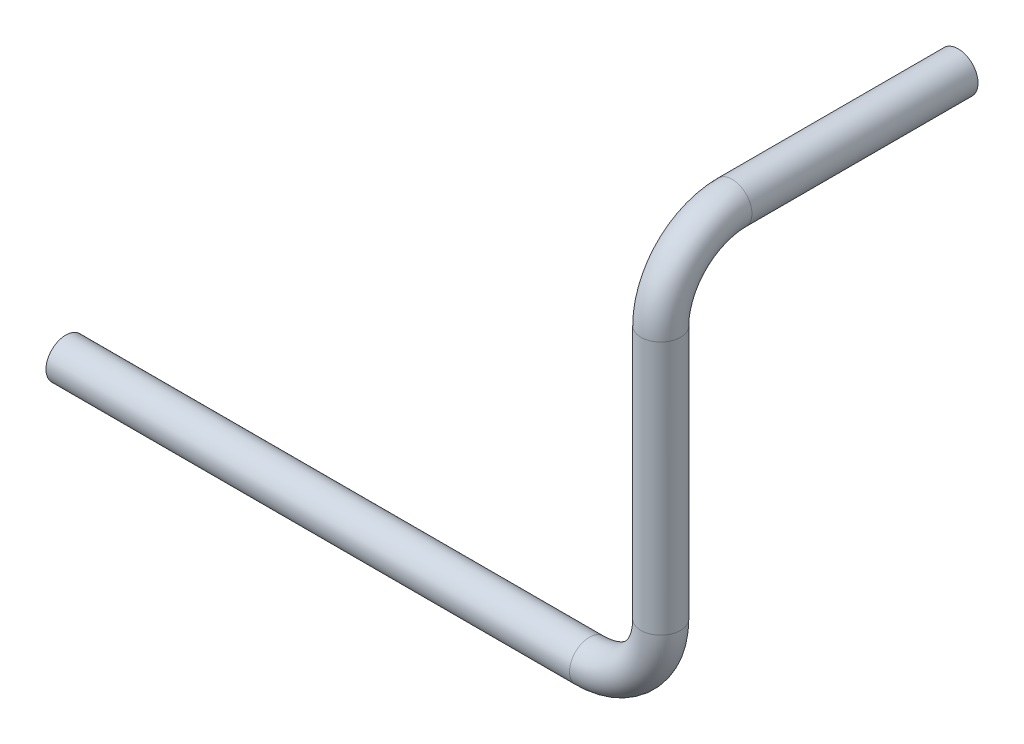
from build123d import *

# Parameters (mm, degrees)
SKIZZE1_R   = 10
SKIZZE1_R_2 = 9


with BuildPart() as part:
    # Austragung-Dünn1: sweep along a curve in space
    with BuildLine() as austragung_d_nn1_path:
        Line((0, 0, 0), (264, 0, 0))
        ThreePointArc((264, 0, 0), (289.455844123, 10.544155877, 0), (300, 36, 0))
        Line((300, 36, 0), (300, 164, 0))
        ThreePointArc((300, 164, 0), (300, 189.455844123, -10.544155877), (300, 200, -36))
        Line((300, 200, -36), (300, 200, -150))
    # Skizze1 → Austragung-Dünn1 (sweep)
    with BuildSketch(Plane(origin=(0, 0, 0), x_dir=(0, 0, -1), z_dir=(1, 0, 0))):
        Circle(SKIZZE1_R)
        Circle(SKIZZE1_R_2, mode=Mode.SUBTRACT)
    sweep(path=austragung_d_nn1_path.line)


solid = part.part
